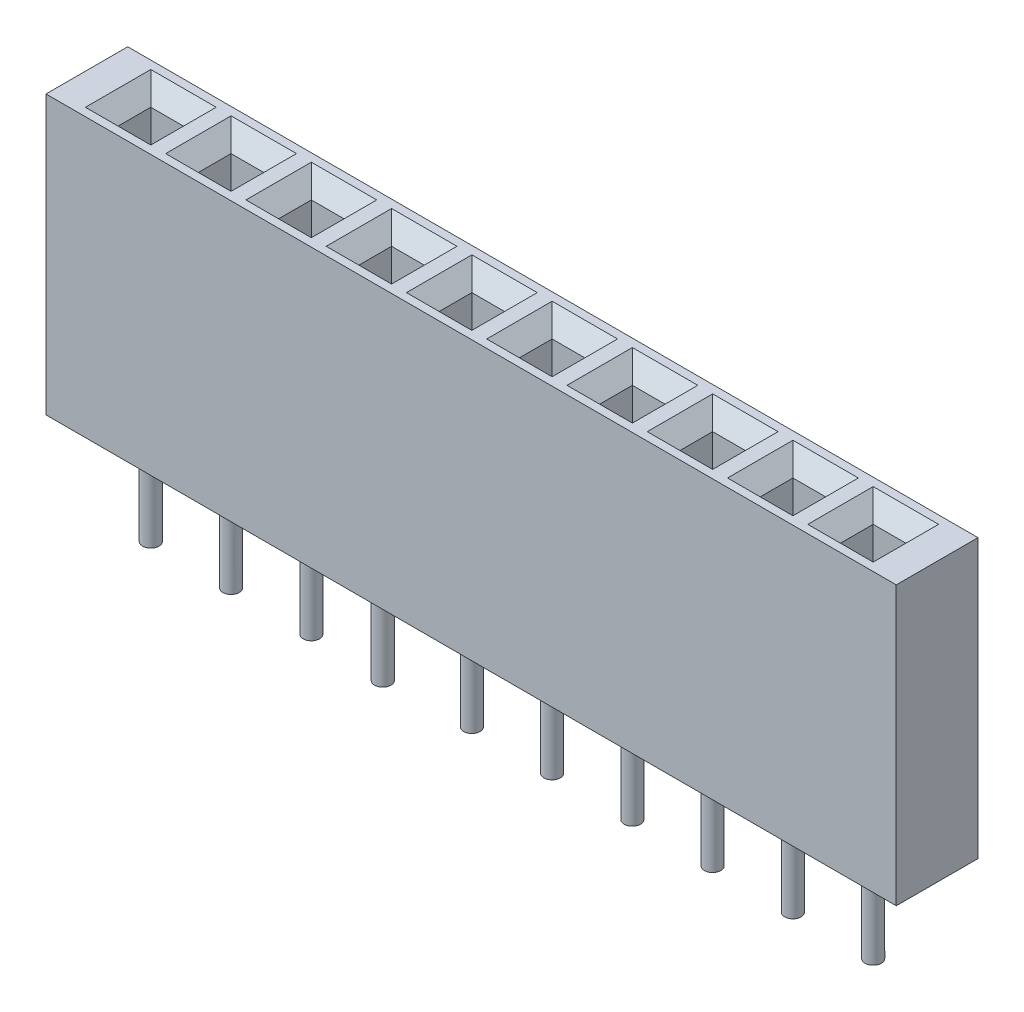
from build123d import *

# Parameters (mm, degrees)
SKETCH1_W           = 26
SKETCH1_H           = 2.5
BOSS_EXTRUDE1_DEPTH = 8.5
SKETCH2_W           = 1
SKETCH2_H           = 1
CUT_EXTRUDE1_DEPTH  = 5
CHAMFER1_SIZE       = 0.5
SKETCH3_R           = 0.25
BOSS_EXTRUDE2_DEPTH = 6.5


with BuildPart() as part:
    # Sketch1 → Boss-Extrude1 (new body)
    with BuildSketch(Plane(origin=(0, 0, 0), x_dir=(1, 0, 0), z_dir=(0, 1, 0))):
        with Locations((13, 1.25)):
            Rectangle(SKETCH1_W, SKETCH1_H)
    extrude(amount=BOSS_EXTRUDE1_DEPTH)

    # Sketch2 → Cut-Extrude1 (cut)
    with BuildSketch(Plane(origin=(0, 8.5, 0), x_dir=(1, 0, 0), z_dir=(0, 1, 0))):
        with Locations((1.9545, 1.25)):
            Rectangle(SKETCH2_W, SKETCH2_H)
        with Locations((4.409, 1.25)):
            Rectangle(SKETCH2_W, SKETCH2_H)
        with Locations((6.8635, 1.25)):
            Rectangle(SKETCH2_W, SKETCH2_H)
        with Locations((9.318, 1.25)):
            Rectangle(SKETCH2_W, SKETCH2_H)
        with Locations((11.7725, 1.25)):
            Rectangle(SKETCH2_W, SKETCH2_H)
        with Locations((14.227, 1.25)):
            Rectangle(SKETCH2_W, SKETCH2_H)
        with Locations((16.6815, 1.25)):
            Rectangle(SKETCH2_W, SKETCH2_H)
        with Locations((19.136, 1.25)):
            Rectangle(SKETCH2_W, SKETCH2_H)
        with Locations((21.5905, 1.25)):
            Rectangle(SKETCH2_W, SKETCH2_H)
        with Locations((24.045, 1.25)):
            Rectangle(SKETCH2_W, SKETCH2_H)
    extrude(amount=-CUT_EXTRUDE1_DEPTH, mode=Mode.SUBTRACT)

    # Chamfer1
    chamfer1_edges = [part.edges().sort_by_distance(p)[0] for p in [
        (21.0905, 8.5, -1.25),
        (21.5905, 8.5, -0.75),
        (22.0905, 8.5, -1.25),
        (21.5905, 8.5, -1.75),
        (23.545, 8.5, -1.25),
        (24.045, 8.5, -0.75),
        (24.545, 8.5, -1.25),
        (24.045, 8.5, -1.75),
        (1.4545, 8.5, -1.25),
        (1.9545, 8.5, -0.75),
        (2.4545, 8.5, -1.25),
        (1.9545, 8.5, -1.75),
        (3.909, 8.5, -1.25),
        (4.409, 8.5, -0.75),
        (4.909, 8.5, -1.25),
        (4.409, 8.5, -1.75),
        (6.3635, 8.5, -1.25),
        (6.8635, 8.5, -0.75),
        (7.3635, 8.5, -1.25),
        (6.8635, 8.5, -1.75),
        (8.818, 8.5, -1.25),
        (9.318, 8.5, -0.75),
        (9.818, 8.5, -1.25),
        (9.318, 8.5, -1.75),
        (11.2725, 8.5, -1.25),
        (11.7725, 8.5, -0.75),
        (12.2725, 8.5, -1.25),
        (11.7725, 8.5, -1.75),
        (13.727, 8.5, -1.25),
        (14.227, 8.5, -0.75),
        (14.727, 8.5, -1.25),
        (14.227, 8.5, -1.75),
        (16.1815, 8.5, -1.25),
        (16.6815, 8.5, -0.75),
        (17.1815, 8.5, -1.25),
        (16.6815, 8.5, -1.75),
        (18.636, 8.5, -1.25),
        (19.136, 8.5, -0.75),
        (19.636, 8.5, -1.25),
        (19.136, 8.5, -1.75),
    ]]
    chamfer(chamfer1_edges, length=CHAMFER1_SIZE)

    # Sketch3 → Boss-Extrude2 (add)
    with BuildSketch(Plane(origin=(0, 3.5, 0), x_dir=(1, 0, 0), z_dir=(0, 1, 0))):
        with Locations((1.9545, 1.25)):
            Circle(SKETCH3_R)
        with Locations((4.409, 1.25)):
            Circle(SKETCH3_R)
        with Locations((6.8635, 1.25)):
            Circle(SKETCH3_R)
        with Locations((9.183250215, 1.115250215)):
            Circle(SKETCH3_R)
        with Locations((11.7725, 1.25)):
            Circle(SKETCH3_R)
        with Locations((14.227, 1.25)):
            Circle(SKETCH3_R)
        with Locations((16.6815, 1.25)):
            Circle(SKETCH3_R)
        with Locations((19.136, 1.25)):
            Circle(SKETCH3_R)
        with Locations((21.5905, 1.25)):
            Circle(SKETCH3_R)
        with Locations((24.045, 1.25)):
            Circle(SKETCH3_R)
    extrude(amount=-BOSS_EXTRUDE2_DEPTH)


solid = part.part
